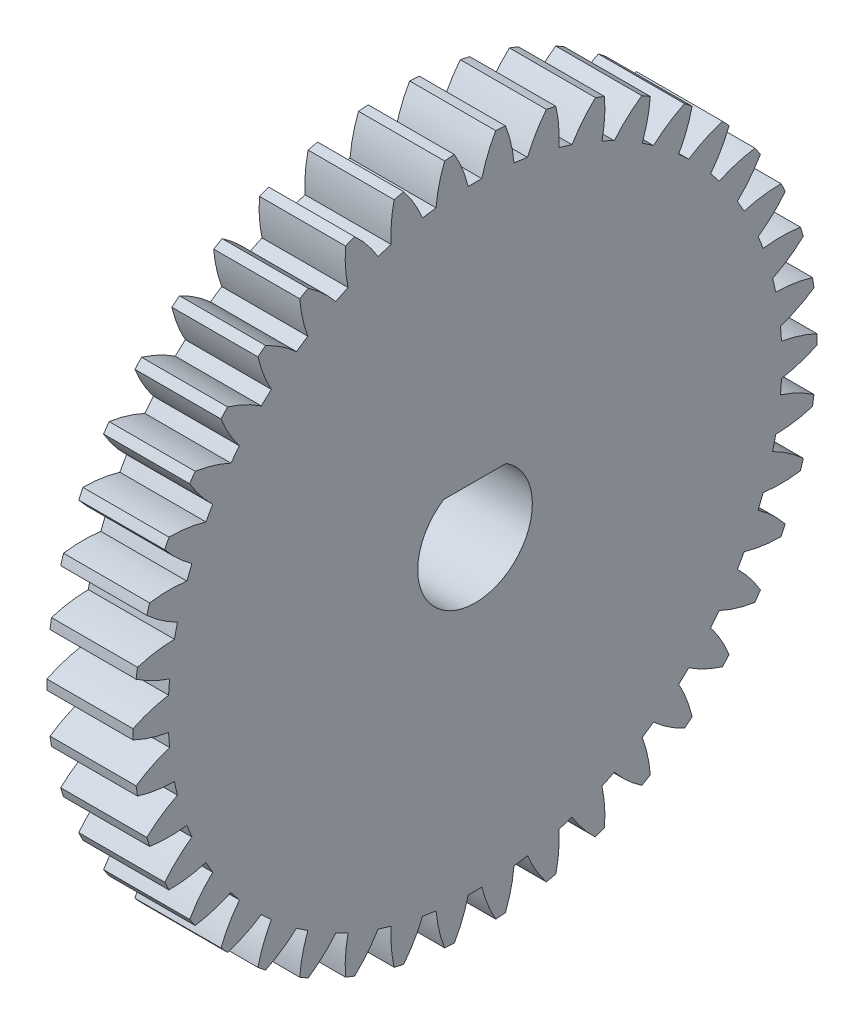
from build123d import *

# Parameters (mm, degrees)
BASPROSKE_W        = 4.3942
BASPROSKE_H        = 17.4625
TOOTHCUT_DEPTH     = 26.083596356
TEETHCUTS_COUNT    = 42
TEETHCUTS_ANGLE    = 351.428571429
BORSKE_R           = 0.396875
BORE_DEPTH         = 50.8000508
CUT_EXTRUDE1_DEPTH = 7.366


with BuildPart() as part:
    # BasProSke → Base-Revolve (revolve)
    with BuildSketch(Plane(origin=(0, 0, 0), x_dir=(1, 0, 0), z_dir=(0, 1, 0)), mode=Mode.PRIVATE) as base_revolve_sk:
        with Locations((2.1971, 8.73125)):
            Rectangle(BASPROSKE_W, BASPROSKE_H)
    revolve(base_revolve_sk.sketch.rotate(Axis((-10, 0, 0), (1, 0, 0)), 180), axis=Axis((-10, 0, 0), (1, 0, 0)))

    # TooCutSke → ToothCut (cut, through all)
    with BuildSketch(Plane(origin=(0, 0, 0), x_dir=(0, 0, -1), z_dir=(1, 0, 0))):
        with BuildLine():
            ThreePointArc((0.348764079, 15.661567205), (0, 15.66545), (-0.348764079, 15.661567205))
            ThreePointArc((-0.348764079, 15.661567205), (-0.644200617, 16.584632497), (-1.070338344, 17.455114501))
            ThreePointArc((-1.070338344, 17.455114501), (0, 17.4879), (1.070338344, 17.455114501))
            ThreePointArc((1.070338344, 17.455114501), (0.644200617, 16.584632497), (0.348764079, 15.661567205))
        make_face()
    toothcut = extrude(amount=TOOTHCUT_DEPTH, mode=Mode.SUBTRACT)

    # TeethCuts: ToothCut ×42 about axis
    teethcuts_axis = Axis((-10, 0, 0), (1, 0, 0))
    for i in range(1, TEETHCUTS_COUNT):
        add(toothcut.rotate(teethcuts_axis, i * TEETHCUTS_ANGLE / (TEETHCUTS_COUNT - 1)), mode=Mode.SUBTRACT)

    # BorSke → Bore (cut, symmetric)
    with BuildSketch(Plane(origin=(0, 0, 0), x_dir=(0, 0, -1), z_dir=(1, 0, 0))):
        with Locations(Location((0, 0, 0), (0, 0, 180))):
            Circle(BORSKE_R)
    extrude(amount=BORE_DEPTH, both=True, mode=Mode.SUBTRACT)

    # Sketch1 → Cut-Extrude1 (cut)
    with BuildSketch(Plane(origin=(4.3942, 0, 0), x_dir=(0, 0, -1), z_dir=(1, 0, 0))):
        with BuildLine():
            Line((-1.597850118, 2.45), (1.597850118, 2.45))
            ThreePointArc((1.597850118, 2.45), (0, -2.925), (-1.597850118, 2.45))
        make_face()
    extrude(amount=-CUT_EXTRUDE1_DEPTH, mode=Mode.SUBTRACT)


solid = part.part
